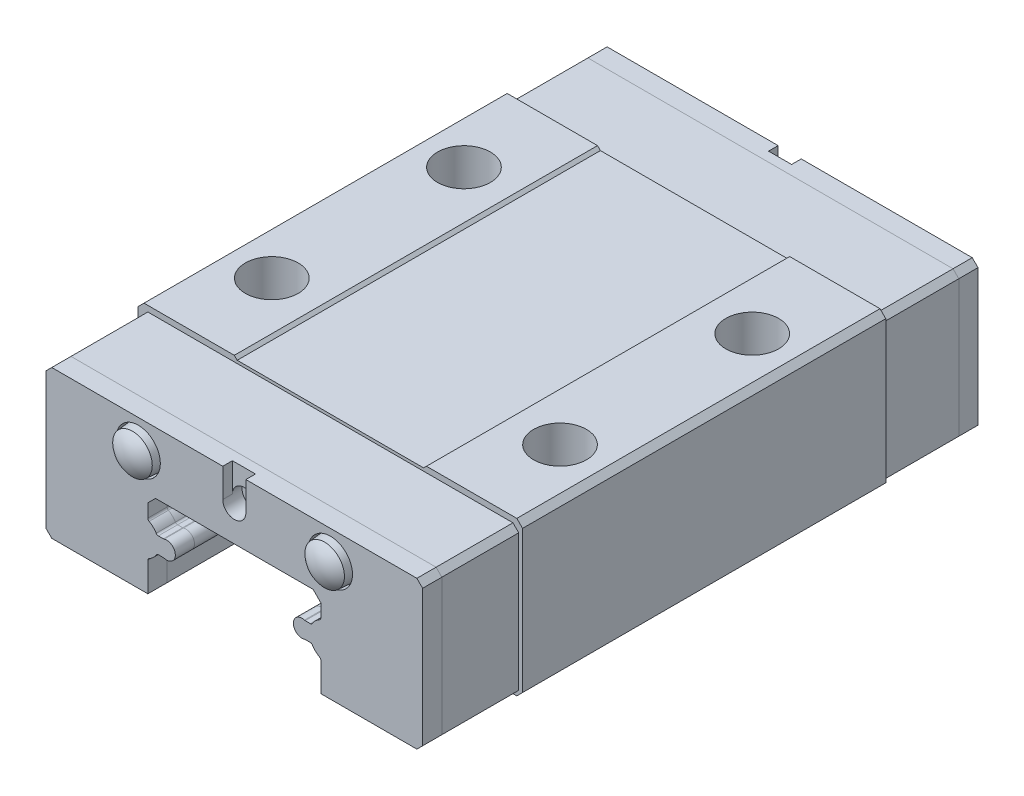
from build123d import *

# Parameters (mm, degrees)
BOSS_EXTRUDE1_DEPTH = 9.45
BOSS_EXTRUDE2_DEPTH = 4
BOSS_EXTRUDE3_DEPTH = 1
SKETCH5_R           = 0.6
CUT_EXTRUDE2_DEPTH  = 24.9
SKETCH6_R           = 1.15
SKETCH6_W           = 1.2
SKETCH6_H           = 1.5
CUT_EXTRUDE3_DEPTH  = 0.5
LPATTERN1_COUNT     = 2
LPATTERN1_PITCH     = 10
SKETCH2_R           = 1.375
CUT_EXTRUDE1_DEPTH  = 2.5


with BuildPart() as part:
    # Sketch1 → Boss-Extrude1 (new body, symmetric)
    with BuildSketch(Plane.XY):
        with BuildLine():
            Line((4.5, 0), (9.7, 0))
            Line((9.7, 0), (10, 0.3))
            Line((10, 0.3), (10, 7.7))
            Line((10, 7.7), (9.7, 8))
            Line((9.7, 8), (5, 8))
            Line((5, 8), (4.85, 7.85))
            Line((4.85, 7.85), (-4.85, 7.85))
            Line((-4.85, 7.85), (-5, 8))
            Line((-5, 8), (-9.7, 8))
            Line((-9.7, 8), (-10, 7.7))
            Line((-10, 7.7), (-10, 0.3))
            Line((-10, 0.3), (-9.7, 0))
            Line((-9.7, 0), (-4.5, 0))
            Line((-4.5, 0), (-4.5, 1.508002101))
            ThreePointArc((-4.5, 1.508002101), (-4.481535993, 1.574783253), (-4.431388889, 1.622594441))
            ThreePointArc((-4.431388889, 1.622594441), (-4.224528747, 1.772353698), (-4.065036084, 1.971805556))
            ThreePointArc((-4.065036084, 1.971805556), (-4.01760557, 2.018103321), (-3.953514706, 2.035))
            Line((-3.953514706, 2.035), (-3.688448805, 2.035))
            ThreePointArc((-3.688448805, 2.035), (-3.669364148, 2.033591508), (-3.650693039, 2.029396552))
            ThreePointArc((-3.650693039, 2.029396552), (-3.07, 2.46), (-3.650693039, 2.890603448))
            ThreePointArc((-3.650693039, 2.890603448), (-3.669364148, 2.886408492), (-3.688448805, 2.885))
            Line((-3.688448805, 2.885), (-3.953514706, 2.885))
            ThreePointArc((-3.953514706, 2.885), (-4.01760557, 2.901896679), (-4.065036084, 2.948194444))
            ThreePointArc((-4.065036084, 2.948194444), (-4.224528747, 3.147646302), (-4.431388889, 3.297405559))
            ThreePointArc((-4.431388889, 3.297405559), (-4.481535993, 3.345216747), (-4.5, 3.411997899))
            Line((-4.5, 3.411997899), (-4.5, 4.1))
            Line((-4.5, 4.1), (-4.1, 4.5))
            Line((-4.1, 4.5), (4.1, 4.5))
            Line((4.1, 4.5), (4.5, 4.1))
            Line((4.5, 4.1), (4.5, 3.411997899))
            ThreePointArc((4.5, 3.411997899), (4.481535993, 3.345216747), (4.431388889, 3.297405559))
            ThreePointArc((4.431388889, 3.297405559), (4.224528747, 3.147646302), (4.065036084, 2.948194444))
            ThreePointArc((4.065036084, 2.948194444), (4.01760557, 2.901896679), (3.953514706, 2.885))
            Line((3.953514706, 2.885), (3.688448805, 2.885))
            ThreePointArc((3.688448805, 2.885), (3.669364148, 2.886408492), (3.650693039, 2.890603448))
            ThreePointArc((3.650693039, 2.890603448), (3.07, 2.46), (3.650693039, 2.029396552))
            ThreePointArc((3.650693039, 2.029396552), (3.669364148, 2.033591508), (3.688448805, 2.035))
            Line((3.688448805, 2.035), (3.953514706, 2.035))
            ThreePointArc((3.953514706, 2.035), (4.01760557, 2.018103321), (4.065036084, 1.971805556))
            ThreePointArc((4.065036084, 1.971805556), (4.224528747, 1.772353698), (4.431388889, 1.622594441))
            ThreePointArc((4.431388889, 1.622594441), (4.481535993, 1.574783253), (4.5, 1.508002101))
            Line((4.5, 1.508002101), (4.5, 0))
        make_face()
    extrude(amount=BOSS_EXTRUDE1_DEPTH, both=True)

    # Sketch2 → Cut-Extrude1 (cut)
    with BuildSketch(Plane(origin=(0, 8, 0), x_dir=(1, 0, 0), z_dir=(0, 1, 0))):
        with Locations((-7.5, 5)):
            Circle(SKETCH2_R)
        with Locations((7.5, 5)):
            Circle(SKETCH2_R)
        with Locations((7.5, -5)):
            Circle(SKETCH2_R)
        with Locations((-7.5, -5)):
            Circle(SKETCH2_R)
    extrude(amount=-CUT_EXTRUDE1_DEPTH, mode=Mode.SUBTRACT)


with BuildPart() as body_2:
    # Sketch3 → Boss-Extrude2 (new body)
    with BuildSketch(Plane.XY.offset(9.45)):
        with BuildLine():
            Line((9.5, 0), (9.8, 0.3))
            Line((9.8, 0.3), (9.8, 7.4))
            Line((9.8, 7.4), (9.5, 7.7))
            Line((9.5, 7.7), (-9.5, 7.7))
            Line((-9.5, 7.7), (-9.8, 7.4))
            Line((-9.8, 7.4), (-9.8, 0.3))
            Line((-9.8, 0.3), (-9.5, 0))
            Line((-9.5, 0), (-4.5, 0))
            Line((-4.5, 0), (-4.5, 1.508002101))
            ThreePointArc((-4.5, 1.508002101), (-4.481535993, 1.574783253), (-4.431388889, 1.622594441))
            ThreePointArc((-4.431388889, 1.622594441), (-4.224528747, 1.772353698), (-4.065036084, 1.971805556))
            ThreePointArc((-4.065036084, 1.971805556), (-4.01760557, 2.018103321), (-3.953514706, 2.035))
            Line((-3.953514706, 2.035), (-3.688448805, 2.035))
            ThreePointArc((-3.688448805, 2.035), (-3.669364148, 2.033591508), (-3.650693039, 2.029396552))
            ThreePointArc((-3.650693039, 2.029396552), (-3.07, 2.46), (-3.650693039, 2.890603448))
            ThreePointArc((-3.650693039, 2.890603448), (-3.669364148, 2.886408492), (-3.688448805, 2.885))
            Line((-3.688448805, 2.885), (-3.953514706, 2.885))
            ThreePointArc((-3.953514706, 2.885), (-4.01760557, 2.901896679), (-4.065036084, 2.948194444))
            ThreePointArc((-4.065036084, 2.948194444), (-4.224528747, 3.147646302), (-4.431388889, 3.297405559))
            ThreePointArc((-4.431388889, 3.297405559), (-4.481535993, 3.345216747), (-4.5, 3.411997899))
            Line((-4.5, 3.411997899), (-4.5, 4.1))
            Line((-4.5, 4.1), (-4.1, 4.5))
            Line((-4.1, 4.5), (4.1, 4.5))
            Line((4.1, 4.5), (4.5, 4.1))
            Line((4.5, 4.1), (4.5, 3.411997899))
            ThreePointArc((4.5, 3.411997899), (4.481535993, 3.345216747), (4.431388889, 3.297405559))
            ThreePointArc((4.431388889, 3.297405559), (4.224528747, 3.147646302), (4.065036084, 2.948194444))
            ThreePointArc((4.065036084, 2.948194444), (4.01760557, 2.901896679), (3.953514706, 2.885))
            Line((3.953514706, 2.885), (3.688448805, 2.885))
            ThreePointArc((3.688448805, 2.885), (3.669364148, 2.886408492), (3.650693039, 2.890603448))
            ThreePointArc((3.650693039, 2.890603448), (3.07, 2.46), (3.650693039, 2.029396552))
            ThreePointArc((3.650693039, 2.029396552), (3.669364148, 2.033591508), (3.688448805, 2.035))
            Line((3.688448805, 2.035), (3.953514706, 2.035))
            ThreePointArc((3.953514706, 2.035), (4.01760557, 2.018103321), (4.065036084, 1.971805556))
            ThreePointArc((4.065036084, 1.971805556), (4.224528747, 1.772353698), (4.431388889, 1.622594441))
            ThreePointArc((4.431388889, 1.622594441), (4.481535993, 1.574783253), (4.5, 1.508002101))
            Line((4.5, 1.508002101), (4.5, 0))
            Line((4.5, 0), (9.5, 0))
        make_face()
    extrude(amount=BOSS_EXTRUDE2_DEPTH)


with BuildPart() as body_3:
    # Sketch4 → Boss-Extrude3 (new body)
    with BuildSketch(Plane.XY.offset(13.45)):
        with BuildLine():
            Line((-4.5, 0), (-4.5, 1.508002101))
            ThreePointArc((-4.5, 1.508002101), (-4.481535993, 1.574783253), (-4.431388889, 1.622594441))
            ThreePointArc((-4.431388889, 1.622594441), (-4.224528747, 1.772353698), (-4.065036084, 1.971805556))
            ThreePointArc((-4.065036084, 1.971805556), (-4.01760557, 2.018103321), (-3.953514706, 2.035))
            Line((-3.953514706, 2.035), (-3.688448805, 2.035))
            ThreePointArc((-3.688448805, 2.035), (-3.669364148, 2.033591508), (-3.650693039, 2.029396552))
            ThreePointArc((-3.650693039, 2.029396552), (-3.07, 2.46), (-3.650693039, 2.890603448))
            ThreePointArc((-3.650693039, 2.890603448), (-3.669364148, 2.886408492), (-3.688448805, 2.885))
            Line((-3.688448805, 2.885), (-3.953514706, 2.885))
            ThreePointArc((-3.953514706, 2.885), (-4.01760557, 2.901896679), (-4.065036084, 2.948194444))
            ThreePointArc((-4.065036084, 2.948194444), (-4.224528747, 3.147646302), (-4.431388889, 3.297405559))
            ThreePointArc((-4.431388889, 3.297405559), (-4.481535993, 3.345216747), (-4.5, 3.411997899))
            Line((-4.5, 3.411997899), (-4.5, 4.1))
            Line((-4.5, 4.1), (-4.1, 4.5))
            Line((-4.1, 4.5), (4.1, 4.5))
            Line((4.1, 4.5), (4.5, 4.1))
            Line((4.5, 4.1), (4.5, 3.411997899))
            ThreePointArc((4.5, 3.411997899), (4.481535993, 3.345216747), (4.431388889, 3.297405559))
            ThreePointArc((4.431388889, 3.297405559), (4.224528747, 3.147646302), (4.065036084, 2.948194444))
            ThreePointArc((4.065036084, 2.948194444), (4.01760557, 2.901896679), (3.953514706, 2.885))
            Line((3.953514706, 2.885), (3.688448805, 2.885))
            ThreePointArc((3.688448805, 2.885), (3.669364148, 2.886408492), (3.650693039, 2.890603448))
            ThreePointArc((3.650693039, 2.890603448), (3.07, 2.46), (3.650693039, 2.029396552))
            ThreePointArc((3.650693039, 2.029396552), (3.669364148, 2.033591508), (3.688448805, 2.035))
            Line((3.688448805, 2.035), (3.953514706, 2.035))
            ThreePointArc((3.953514706, 2.035), (4.01760557, 2.018103321), (4.065036084, 1.971805556))
            ThreePointArc((4.065036084, 1.971805556), (4.224528747, 1.772353698), (4.431388889, 1.622594441))
            ThreePointArc((4.431388889, 1.622594441), (4.481535993, 1.574783253), (4.5, 1.508002101))
            Line((4.5, 1.508002101), (4.5, 0))
            Line((4.5, 0), (9.5, 0))
            Line((9.5, 0), (9.8, 0.3))
            Line((9.8, 0.3), (9.8, 7.4))
            Line((9.8, 7.4), (9.5, 7.7))
            Line((9.5, 7.7), (-9.5, 7.7))
            Line((-9.5, 7.7), (-9.8, 7.4))
            Line((-9.8, 7.4), (-9.8, 0.3))
            Line((-9.8, 0.3), (-9.5, 0))
            Line((-9.5, 0), (-4.5, 0))
        make_face()
    extrude(amount=BOSS_EXTRUDE3_DEPTH)

    # Sketch5 → Cut-Extrude2 (cut, through all)
    with BuildSketch(Plane.XY.offset(14.45)):
        with Locations((0, 6.2)):
            Circle(SKETCH5_R)
    extrude(amount=-CUT_EXTRUDE2_DEPTH, mode=Mode.SUBTRACT)

    # Sketch6 → Cut-Extrude3 (cut)
    with BuildSketch(Plane.XY.offset(14.45)):
        with Locations((-5, 6.2)):
            Circle(SKETCH6_R)
        with Locations((5, 6.2)):
            Circle(SKETCH6_R)
        with Locations((0, 6.95)):
            Rectangle(SKETCH6_W, SKETCH6_H)
    extrude(amount=-CUT_EXTRUDE3_DEPTH, mode=Mode.SUBTRACT)


with BuildPart() as body_4:
    # Sketch7 → Revolve1 (revolve)
    with BuildSketch(Plane(origin=(0, 6.2, 0), x_dir=(1, 0, 0), z_dir=(0, 1, 0))):
        with BuildLine():
            Line((-5, -13.95), (-3.9, -13.95))
            Line((-3.9, -13.95), (-3.969990931, -14.75))
            ThreePointArc((-3.969990931, -14.75), (-4.447524054, -15.046489733), (-5, -15.15))
            Line((-5, -15.15), (-5, -13.95))
        make_face()
    revolve(axis=Axis((-5, 6.2, 13.95), (0, 0, 1)))


with BuildPart() as lpattern1_1:
    # LPattern1: pattern copy
    add(body_4.part.moved(Location(Vector(1, 0, 0) * (1 * LPATTERN1_PITCH))))


with BuildPart() as body_6:
    # Mirror1: mirrored copy
    add(body_2.part.mirror(Plane.XY))


with BuildPart() as body_7:
    # Mirror1 2: mirrored copy
    add(body_3.part.mirror(Plane.XY))


with BuildPart() as body_8:
    # Mirror1 3: mirrored copy
    add(body_4.part.mirror(Plane.XY))


with BuildPart() as body_9:
    # Mirror1 4: mirrored copy
    add(lpattern1_1.part.mirror(Plane.XY))


solid = Compound([part.part, body_2.part, body_3.part, body_4.part, lpattern1_1.part, body_6.part, body_7.part, body_8.part, body_9.part])
